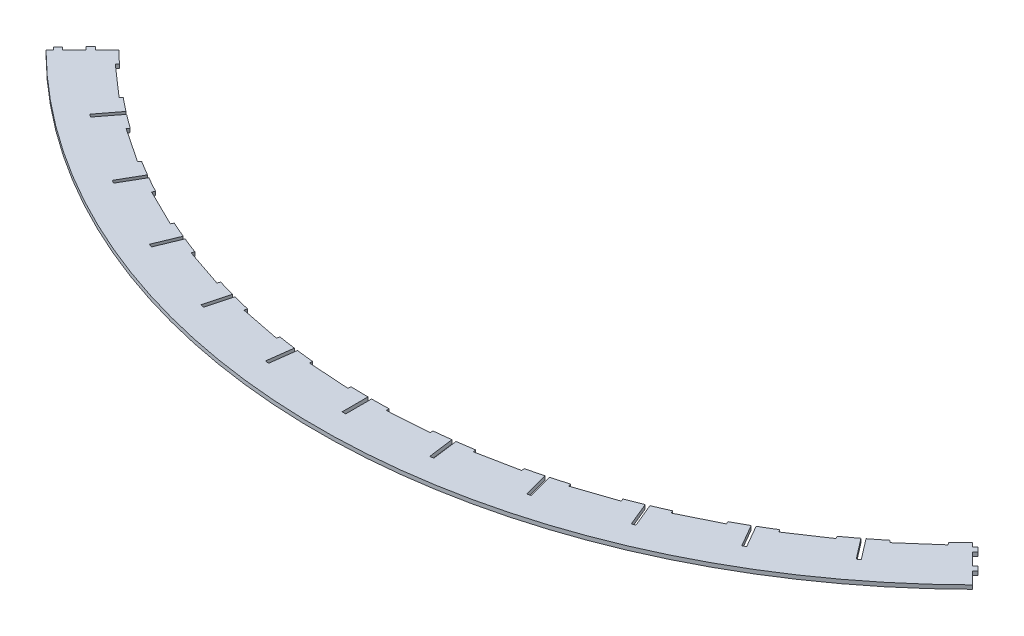
from build123d import *

# Parameters (mm, degrees)
EXTRUDE_1_DEPTH          = 1.5
CUT_EXTRUDE_2_DEPTH      = 1.5
PATTERN_CIRCULAR_1_COUNT = 12
PATTERN_CIRCULAR_1_ANGLE = 82.5
CUT_EXTRUDE_3_DEPTH      = 1.5
PATTERN_CIRCULAR_2_COUNT = 11
PATTERN_CIRCULAR_2_ANGLE = 75
CUT_EXTRUDE_1_REACH      = 3.5
EXTRUDE_2_DEPTH          = 1.5


with BuildPart() as part:
    # 草图1 → 凸台-拉伸1 (new body)
    with BuildSketch(Plane(origin=(0, 0, 0), x_dir=(1, 0, 0), z_dir=(0, 1, 0))):
        with BuildLine():
            Line((-165.901393002, -165.901393002), (-180.043528626, -180.043528626))
            ThreePointArc((-180.043528626, -180.043528626), (0, -254.62), (180.043528626, -180.043528626))
            Line((180.043528626, -180.043528626), (165.901393002, -165.901393002))
            ThreePointArc((165.901393002, -165.901393002), (0, -234.62), (-165.901393002, -165.901393002))
        make_face()
    extrude(amount=EXTRUDE_1_DEPTH)

    # 草图4 → 切除-拉伸2 (cut)
    with BuildSketch(Plane(origin=(0, 1.5, 0), x_dir=(1, 0, 0), z_dir=(0, 1, 0))):
        Polygon((-161.369779414, -171.873728917), (-160.051087784, -170.370049302), (-148.021650864, -180.919582344), (-149.340342494, -182.423261959), align=None)
    cut_extrude_2 = extrude(amount=-CUT_EXTRUDE_2_DEPTH, mode=Mode.SUBTRACT)

    # 阵列(圆周)1: 切除-拉伸2 ×12 about axis
    pattern_circular_1_axis = Axis((0, 0, 0), (0, 1, 0))
    for i in range(1, PATTERN_CIRCULAR_1_COUNT):
        add(cut_extrude_2.rotate(pattern_circular_1_axis, i * PATTERN_CIRCULAR_1_ANGLE / (PATTERN_CIRCULAR_1_COUNT - 1)), mode=Mode.SUBTRACT)

    # 草图5 → 切除-拉伸3 (cut)
    with BuildSketch(Plane(origin=(0, 1.5, 0), x_dir=(1, 0, 0), z_dir=(0, 1, 0))):
        Polygon((-149.470568102, -193.643961102), (-137.295339522, -177.776894296), (-136.184644846, -178.629160297), (-148.359873426, -194.496227102), align=None)
    cut_extrude_3 = extrude(amount=-CUT_EXTRUDE_3_DEPTH, mode=Mode.SUBTRACT)

    # 阵列(圆周)2: 切除-拉伸3 ×11 about axis
    pattern_circular_2_axis = Axis((0, 0, 0), (0, 1, 0))
    for i in range(1, PATTERN_CIRCULAR_2_COUNT):
        add(cut_extrude_3.rotate(pattern_circular_2_axis, i * PATTERN_CIRCULAR_2_ANGLE / (PATTERN_CIRCULAR_2_COUNT - 1)), mode=Mode.SUBTRACT)

    # 草图2 → 切除-拉伸1 (cut, up to next)
    with BuildSketch(Plane(origin=(0, 1.5, 0), x_dir=(1, 0, 0), z_dir=(0, 1, 0)), mode=Mode.PRIVATE) as cut_extrude_1_sk1:
        Polygon((-186.109121992, -185.04846182), (-149.864335916, -148.803675744), (-148.803675744, -149.864335916), (-185.04846182, -186.109121992), align=None)
    cut_extrude_1_tool1 = extrude(cut_extrude_1_sk1.sketch, amount=-CUT_EXTRUDE_1_REACH, mode=Mode.PRIVATE) & part.part
    add(cut_extrude_1_tool1.solids().sort_by_distance((-167.456399, 1.5, 167.456399))[0], mode=Mode.SUBTRACT)
    # 草图2 → 切除-拉伸1 (cut, up to next)
    with BuildSketch(Plane(origin=(0, 1.5, 0), x_dir=(1, 0, 0), z_dir=(0, 1, 0)), mode=Mode.PRIVATE) as cut_extrude_1_sk2:
        Polygon((182.043517249, -183.10417742), (140.820272757, -141.880932929), (141.880932929, -140.820272757), (183.10417742, -182.043517249), align=None)
    cut_extrude_1_tool2 = extrude(cut_extrude_1_sk2.sketch, amount=-CUT_EXTRUDE_1_REACH, mode=Mode.PRIVATE) & part.part
    add(cut_extrude_1_tool2.solids().sort_by_distance((161.962225, 1.5, 161.962225))[0], mode=Mode.SUBTRACT)

    # 草图3 → 凸台-拉伸2 (add)
    with BuildSketch(Plane(origin=(0, 1.5, 0), x_dir=(1, 0, 0), z_dir=(0, 1, 0))):
        Polygon((173.148389865, -174.209050037), (174.916156818, -175.97681699), (175.97681699, -174.916156818), (174.209050037, -173.148389865), align=None)
        Polygon((168.552195787, -169.612855959), (166.784428834, -167.845089006), (167.845089006, -166.784428834), (169.612855959, -168.552195787), align=None)
        Polygon((-178.098203915, -179.158864086), (-176.330436962, -177.391097133), (-177.391097133, -176.330436962), (-179.158864086, -178.098203915), align=None)
        Polygon((-171.734242884, -172.794903056), (-169.966475931, -171.027136103), (-171.062491442, -169.931120592), (-172.830258395, -171.698887545), align=None)
    extrude(amount=-EXTRUDE_2_DEPTH)


solid = part.part
